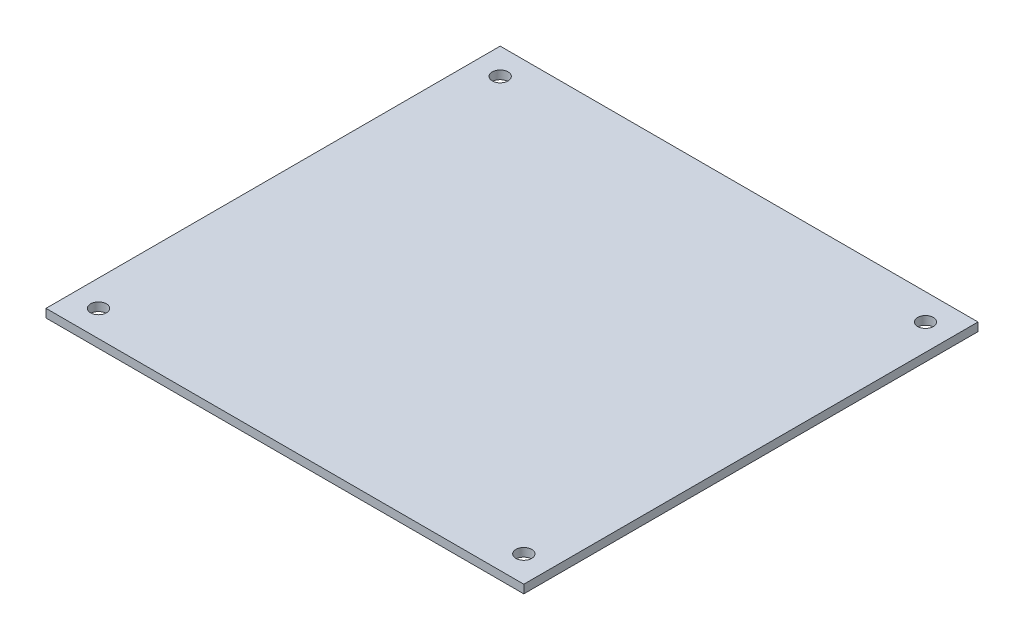
from build123d import *

# Parameters (mm, degrees)
SKETCH2_W          = 91
SKETCH2_H          = 86.5
PCB_DEPTH          = 1.6
CUT_EXTRUDE1_DEPTH = 10


with BuildPart() as part:
    # Sketch2 → PCB (new body)
    with BuildSketch(Plane(origin=(0, 0, 0), x_dir=(1, 0, 0), z_dir=(0, 1, 0))):
        with Locations((45.5, 43.25)):
            Rectangle(SKETCH2_W, SKETCH2_H)
    extrude(amount=PCB_DEPTH)

    # Sketch3 → Cut-Extrude1 (cut)
    with BuildSketch(Plane(origin=(0, 1.6, 0), x_dir=(1, 0, 0), z_dir=(0, 1, 0))):
        with BuildLine():
            ThreePointArc((6.5, 5), (6.060660172, 6.060660172), (5, 6.5))
            Line((5, 6.5), (5, 5))
            Line((5, 5), (6.5, 5))
        make_face()
        with BuildLine():
            Line((5, 5), (5, 6.5))
            ThreePointArc((5, 6.5), (3.939339828, 3.939339828), (6.5, 5))
            Line((6.5, 5), (5, 5))
        make_face()
        with BuildLine():
            ThreePointArc((86, 6.5), (84.939339828, 6.060660172), (84.5, 5))
            Line((84.5, 5), (86, 5))
            Line((86, 5), (86, 6.5))
        make_face()
        with BuildLine():
            Line((86, 5), (84.5, 5))
            ThreePointArc((84.5, 5), (86, 3.5), (87.5, 5))
            ThreePointArc((87.5, 5), (87.060660172, 6.060660172), (86, 6.5))
            Line((86, 6.5), (86, 5))
        make_face()
        with BuildLine():
            ThreePointArc((87.5, 81.5), (86, 83), (84.5, 81.5))
            Line((84.5, 81.5), (86, 81.5))
            Line((86, 81.5), (86, 80))
            ThreePointArc((86, 80), (87.060660172, 80.439339828), (87.5, 81.5))
        make_face()
        with BuildLine():
            Line((86, 81.5), (84.5, 81.5))
            ThreePointArc((84.5, 81.5), (84.939339828, 80.439339828), (86, 80))
            Line((86, 80), (86, 81.5))
        make_face()
        with BuildLine():
            Line((6.5, 81.5), (5, 81.5))
            Line((5, 81.5), (5, 80))
            ThreePointArc((5, 80), (6.060660172, 80.439339828), (6.5, 81.5))
        make_face()
        with BuildLine():
            Line((5, 80), (5, 81.5))
            Line((5, 81.5), (6.5, 81.5))
            ThreePointArc((6.5, 81.5), (3.939339828, 82.560660172), (5, 80))
        make_face()
    extrude(amount=-CUT_EXTRUDE1_DEPTH, mode=Mode.SUBTRACT)


solid = part.part
